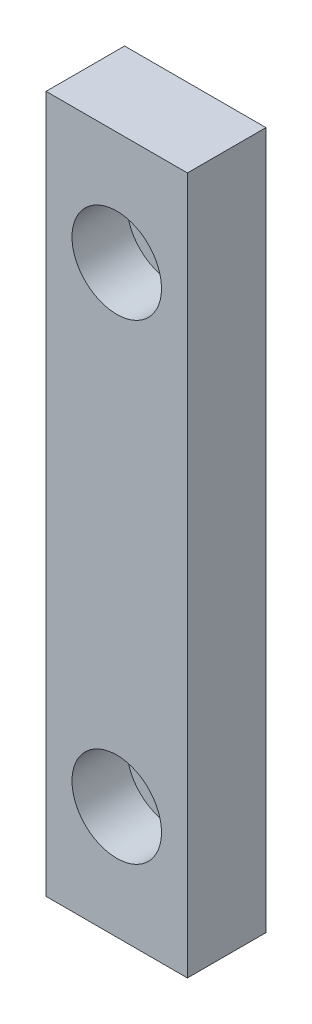
from build123d import *

# Parameters (mm, degrees)
SKETCH1_W           = 44.4
SKETCH1_H           = 9
SKETCH1_R           = 2.85
BOSS_EXTRUDE1_DEPTH = 5
SKETCH1_3_R         = 2.85
SKETCH1_3_R_2       = 1.6
BOSS_EXTRUDE2_DEPTH = 1.5


with BuildPart() as part:
    # Sketch1 → Boss-Extrude1 (new body)
    with BuildSketch(Plane(origin=(0, 0, 0), x_dir=(0, 1, 0), z_dir=(0, 0, 1))):
        Rectangle(SKETCH1_W, SKETCH1_H)
        with Locations((-15, 0)):
            Circle(SKETCH1_R, mode=Mode.SUBTRACT)
        with Locations((15, 0)):
            Circle(SKETCH1_R, mode=Mode.SUBTRACT)
    extrude(amount=BOSS_EXTRUDE1_DEPTH)

    # Sketch1_3 → Boss-Extrude2 (add)
    # profile 1 of 2: a face of its own
    with BuildSketch(Plane(origin=(0, 0, 0), x_dir=(0, 1, 0), z_dir=(0, 0, 1))):
        with Locations((15, 0)):
            Circle(SKETCH1_3_R)
        with Locations((15, 0)):
            Circle(SKETCH1_3_R_2, mode=Mode.SUBTRACT)
    # profile 2 of 2: a face of its own
    with BuildSketch(Plane(origin=(0, 0, 0), x_dir=(0, 1, 0), z_dir=(0, 0, 1))):
        with Locations((-15, 0)):
            Circle(SKETCH1_3_R)
        with Locations((-15, 0)):
            Circle(SKETCH1_3_R_2, mode=Mode.SUBTRACT)
    extrude(amount=BOSS_EXTRUDE2_DEPTH)


solid = part.part
